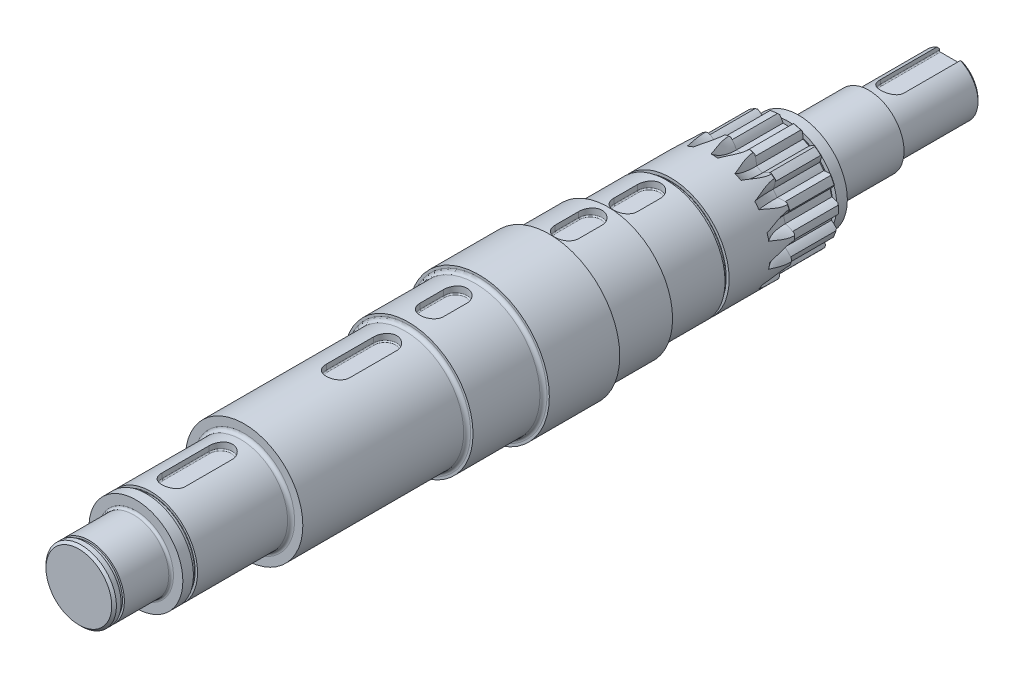
from build123d import *

# Parameters (mm, degrees)
FILLET1_R          = 1.5
FILLET2_R          = 1
CHAMFER1_SIZE      = 1
FILLET3_R          = 0.15
CHAMFER3_SIZE      = 0.5
CUT_EXTRUDE1_DEPTH = 19.85
CHAMFER2_SIZE      = 0.5
CIRPATTERN1_COUNT  = 15
CUT_EXTRUDE3_DEPTH = 3.2
CUT_EXTRUDE4_DEPTH = 3.2
CUT_EXTRUDE5_DEPTH = 3.2
CUT_EXTRUDE6_DEPTH = 3.2
CUT_EXTRUDE7_DEPTH = 3.2
CUT_EXTRUDE8_DEPTH = 3.2
FILLET5_R          = 0.5


with BuildPart() as part:
    # Sketch1 → Revolve1 (revolve)
    with BuildSketch(Plane(origin=(0, 0, 0), x_dir=(0, 0, -1), z_dir=(1, 0, 0))):
        Polygon((0, 0), (371.5, 0), (371.5, 12.5), (336.5, 12.5), (336.5, 15), (306.5, 15), (306.5, 20.85), (302, 20.85), (302, 18.85), (300.25, 18.85), (300.25, 23.85), (280.4, 23.85), (280.4, 25), (252, 25), (252, 23.6), (250.25, 23.6), (250.25, 25), (225.4, 25), (225.4, 27.5), (200.4, 27.5), (200.4, 30), (170.4, 30), (170.4, 27.5), (140.4, 27.5), (140.4, 25), (70.4, 25), (70.4, 20), (30.55, 20), (30.55, 18.85), (28.8, 18.85), (28.8, 20), (24.3, 20), (24.3, 15), (4.4, 15), (4.4, 14.175), (3, 14.175), (3, 15), (0, 15), align=None)
    revolve(axis=Axis((0, 0, 0), (0, 0, -1)))

    # Fillet1
    fillet1_edges = [part.edges().sort_by_distance(p)[0] for p in [
        (0, -20, -70.4),
        (0, -25, -140.4),
        (0, -27.5, -170.4),
        (0, -27.5, -200.4),
        (0, -25, -225.4),
    ]]
    fillet(fillet1_edges, radius=FILLET1_R)

    # Fillet2
    fillet2_edges = [part.edges().sort_by_distance(p)[0] for p in [
        (0, -15, -24.3),
        (0, -15, -306.5),
        (0, -12.5, -336.5),
    ]]
    fillet(fillet2_edges, radius=FILLET2_R)

    # Chamfer1
    chamfer1_edges = [part.edges().sort_by_distance(p)[0] for p in [
        (0, -15, 0),
        (0, -12.5, -371.5),
    ]]
    chamfer(chamfer1_edges, length=CHAMFER1_SIZE)

    # Fillet3
    fillet3_edges = [part.edges().sort_by_distance(p)[0] for p in [
        (0, -18.85, -28.8),
        (0, -18.85, -30.55),
        (0, -23.6, -250.25),
        (0, -23.6, -252),
        (0, -18.85, -300.25),
        (0, -18.85, -302),
    ]]
    fillet(fillet3_edges, radius=FILLET3_R)

    # Chamfer3
    chamfer3_edges = [part.edges().sort_by_distance(p)[0] for p in [
        (0, -23.85, -300.25),
    ]]
    chamfer(chamfer3_edges, length=CHAMFER3_SIZE)

    # Sketch2 → Cut-Extrude1 (cut)
    with BuildSketch(Plane(origin=(0, 0, -300.25), x_dir=(-1, 0, 0), z_dir=(0, 0, -1))):
        with BuildLine():
            ThreePointArc((20.702827631, -2.472939158), (20.822920909, -1.062292244), (20.847007283, 0.353252513))
            add(Edge.make_bspline(
                [(20.847007283, 0.353252513), (20.870243286, 0.362553555), (20.948480631, 0.39428168), (21.08095698, 0.450325268), (21.266105535, 0.533864709), (21.525600946, 0.659940117), (21.832858261, 0.821870901), (22.185751807, 1.026535005), (22.578189501, 1.276626369), (22.969048415, 1.550266678), (23.345923835, 1.834810452), (23.717110083, 2.139366976), (24.069394713, 2.446112914), (24.424634104, 2.781549874), (24.747164799, 3.099800638), (25.095939694, 3.474305801), (25.373794207, 3.781844467), (25.649843367, 4.114023346), (25.782555427, 4.277810204), (25.849678545, 4.362395952)],
                knots=[0.162676894, 0.162676894, 0.162676894, 0.162676894, 0.162676894, 0.174208854, 0.201574955, 0.228941013, 0.256307345, 0.307035032, 0.361767351, 0.41649966, 0.471231936, 0.525964281, 0.580696615, 0.635428982, 0.690161387, 0.744893688, 0.799626083, 0.854358408, 0.909090916, 0.909090916, 0.909090916, 0.909090916, 0.909090916], degree=4))
            ThreePointArc((25.849678545, 4.362395952), (26.181146498, -1.335644936), (25.271531472, -6.970371324))
            add(Edge.make_bspline(
                [(20.702827631, -2.472939158), (20.724996469, -2.484556552), (20.799598782, -2.524081872), (20.925684017, -2.593316115), (21.101369854, -2.695263712), (21.346687839, -2.847092441), (21.635870899, -3.039450944), (21.966104457, -3.278965135), (22.331053903, -3.567695002), (22.692036279, -3.879690889), (23.037998154, -4.201110587), (23.376263772, -4.541860171), (23.695503094, -4.882864256), (24.014762062, -5.252711104), (24.303231119, -5.602132341), (24.612083329, -6.010186695), (24.857198277, -6.344404924), (25.098009704, -6.702951716), (25.213364804, -6.879393851), (25.271531472, -6.970371324)],
                knots=[0.162676894, 0.162676894, 0.162676894, 0.162676894, 0.162676894, 0.174208854, 0.201574955, 0.228941013, 0.256307345, 0.307035032, 0.361767351, 0.41649966, 0.471231936, 0.525964281, 0.580696615, 0.635428982, 0.690161387, 0.744893688, 0.799626083, 0.854358408, 0.909090916, 0.909090916, 0.909090916, 0.909090916, 0.909090916], degree=4))
        make_face()
    cut_extrude1 = extrude(amount=-CUT_EXTRUDE1_DEPTH, mode=Mode.SUBTRACT)

    # Chamfer2
    chamfer2_edges = [part.edges().sort_by_distance(p)[0] for p in [
        (0, -25, -280.4),
    ]]
    chamfer(chamfer2_edges, length=CHAMFER2_SIZE)

    # Sketch4 → Cut-Revolve2 (revolve, cut)
    with BuildSketch(Plane(origin=(0, 0, -280.4), x_dir=(-1, 0, 0), z_dir=(0, 0, -1))):
        with BuildLine():
            Line((37.640883537, 2.485452526), (37.192529976, -6.303118409))
            Line((37.192529976, -6.303118409), (24.333319207, -5.64709902))
            add(Edge.make_bspline(
                [(20.702827631, -2.472939158), (20.724996469, -2.484556552), (20.799598782, -2.524081872), (20.925684017, -2.593316115), (21.101369854, -2.695263712), (21.346687839, -2.847092441), (21.635870899, -3.039450944), (21.966104457, -3.278965135), (22.331053903, -3.567695002), (22.692036279, -3.879690889), (23.037998154, -4.201110587), (23.376263772, -4.541860171), (23.695503094, -4.882864256), (23.98186797, -5.21460481), (24.171234572, -5.442484317), (24.28949356, -5.591203495), (24.333319207, -5.64709902)],
                knots=[0.162676894, 0.162676894, 0.162676894, 0.162676894, 0.162676894, 0.174208854, 0.201574955, 0.228941013, 0.256307345, 0.307035032, 0.361767351, 0.41649966, 0.471231936, 0.525964281, 0.580696615, 0.635428982, 0.690161387, 0.722336815, 0.722336815, 0.722336815, 0.722336815, 0.722336815], degree=4))
            ThreePointArc((20.702827631, -2.472939158), (20.822920909, -1.062292244), (20.847007283, 0.353252513))
            add(Edge.make_bspline(
                [(24.781672768, 3.141471915), (24.732386374, 3.09032655), (24.599606761, 2.954414238), (24.388032855, 2.746988922), (24.069394713, 2.446112914), (23.717110083, 2.139366976), (23.345923835, 1.834810452), (22.969048415, 1.550266678), (22.578189501, 1.276626369), (22.185751807, 1.026535005), (21.832858261, 0.821870901), (21.525600946, 0.659940117), (21.266105535, 0.533864709), (21.08095698, 0.450325268), (20.948480631, 0.39428168), (20.870243286, 0.362553555), (20.847007283, 0.353252513)],
                knots=[0.349430995, 0.349430995, 0.349430995, 0.349430995, 0.349430995, 0.381606423, 0.436338828, 0.491071195, 0.545803528, 0.600535874, 0.655268149, 0.710000458, 0.764732778, 0.815460465, 0.842826797, 0.870192854, 0.897558956, 0.909090916, 0.909090916, 0.909090916, 0.909090916, 0.909090916], degree=4))
            Line((24.781672768, 3.141471915), (37.640883537, 2.485452526))
        make_face()
    cut_revolve2 = revolve(axis=Axis((-37.640883537, 2.485452526, -280.4), (0.050949268, -0.998701243, 0)), mode=Mode.SUBTRACT)

    # CirPattern1: Cut-Extrude1, Cut-Revolve2 ×15 about axis
    cirpattern1_axis = Axis((0, 0, 0), (0, 0, 1))
    for i in range(1, CIRPATTERN1_COUNT):
        add(cut_extrude1.rotate(cirpattern1_axis, i * 360 / CIRPATTERN1_COUNT), mode=Mode.SUBTRACT)
        add(cut_revolve2.rotate(cirpattern1_axis, i * 360 / CIRPATTERN1_COUNT), mode=Mode.SUBTRACT)

    # Sketch5 → Cut-Extrude3 (cut)
    with BuildSketch(Plane(origin=(0, 20, 0), x_dir=(1, 0, 0), z_dir=(0, 1, 0))):
        with BuildLine():
            Line((-5, 60.4), (-5, 40.4))
            ThreePointArc((-5, 40.4), (0, 35.4), (5, 40.4))
            Line((5, 40.4), (5, 60.4))
            ThreePointArc((5, 60.4), (0, 65.4), (-5, 60.4))
        make_face()
    extrude(amount=-CUT_EXTRUDE3_DEPTH, mode=Mode.SUBTRACT)

    # Sketch6 → Cut-Extrude4 (cut)
    with BuildSketch(Plane(origin=(0, 25, 0), x_dir=(1, 0, 0), z_dir=(0, 1, 0))):
        with BuildLine():
            Line((-5, 130.4), (-5, 110.4))
            ThreePointArc((-5, 110.4), (0, 105.4), (5, 110.4))
            Line((5, 110.4), (5, 130.4))
            ThreePointArc((5, 130.4), (0, 135.4), (-5, 130.4))
        make_face()
    extrude(amount=-CUT_EXTRUDE4_DEPTH, mode=Mode.SUBTRACT)

    # Sketch7 → Cut-Extrude5 (cut)
    with BuildSketch(Plane(origin=(0, 27.5, 0), x_dir=(1, 0, 0), z_dir=(0, 1, 0))):
        with BuildLine():
            Line((-5, 160.4), (-5, 150.4))
            ThreePointArc((-5, 150.4), (0, 145.4), (5, 150.4))
            Line((5, 150.4), (5, 160.4))
            ThreePointArc((5, 160.4), (0, 165.4), (-5, 160.4))
        make_face()
    extrude(amount=-CUT_EXTRUDE5_DEPTH, mode=Mode.SUBTRACT)

    # Sketch8 → Cut-Extrude6 (cut)
    with BuildSketch(Plane(origin=(0, 27.5, 0), x_dir=(1, 0, 0), z_dir=(0, 1, 0))):
        with BuildLine():
            Line((5, 207.9), (5, 217.9))
            ThreePointArc((5, 217.9), (0, 222.9), (-5, 217.9))
            Line((-5, 217.9), (-5, 207.9))
            ThreePointArc((-5, 207.9), (0, 202.9), (5, 207.9))
        make_face()
    extrude(amount=-CUT_EXTRUDE6_DEPTH, mode=Mode.SUBTRACT)

    # Sketch9 → Cut-Extrude7 (cut)
    with BuildSketch(Plane(origin=(0, 25, 0), x_dir=(1, 0, 0), z_dir=(0, 1, 0))):
        with BuildLine():
            Line((5, 232.9), (5, 242.9))
            ThreePointArc((5, 242.9), (0, 247.9), (-5, 242.9))
            Line((-5, 242.9), (-5, 232.9))
            ThreePointArc((-5, 232.9), (0, 227.9), (5, 232.9))
        make_face()
    extrude(amount=-CUT_EXTRUDE7_DEPTH, mode=Mode.SUBTRACT)

    # Sketch10 → Cut-Extrude8 (cut)
    with BuildSketch(Plane(origin=(0, 12.5, 0), x_dir=(1, 0, 0), z_dir=(0, 1, 0))):
        with BuildLine():
            Line((-5, 371.5), (-5, 346.5))
            ThreePointArc((-5, 346.5), (0, 341.5), (5, 346.5))
            Line((5, 346.5), (5, 371.5))
            ThreePointArc((5, 371.5), (0, 376.5), (-5, 371.5))
        make_face()
    extrude(amount=-CUT_EXTRUDE8_DEPTH, mode=Mode.SUBTRACT)

    # Fillet5
    fillet5_edges = [part.edges().sort_by_distance(p)[0] for p in [
        (0, 9.3, -341.5),
        (5, 9.3, -359),
        (-5, 9.3, -359),
        (0, 16.8, -65.4),
        (5, 16.8, -50.4),
        (0, 16.8, -35.4),
        (-5, 16.8, -50.4),
        (0, 21.8, -135.4),
        (5, 21.8, -120.4),
        (0, 21.8, -105.4),
        (-5, 21.8, -120.4),
        (0, 24.3, -165.4),
        (5, 24.3, -155.4),
        (0, 24.3, -145.4),
        (-5, 24.3, -155.4),
        (0, 24.3, -202.9),
        (-5, 24.3, -212.9),
        (0, 24.3, -222.9),
        (5, 24.3, -212.9),
        (0, 21.8, -227.9),
        (-5, 21.8, -237.9),
        (0, 21.8, -247.9),
        (5, 21.8, -237.9),
    ]]
    fillet(fillet5_edges, radius=FILLET5_R)


solid = part.part
